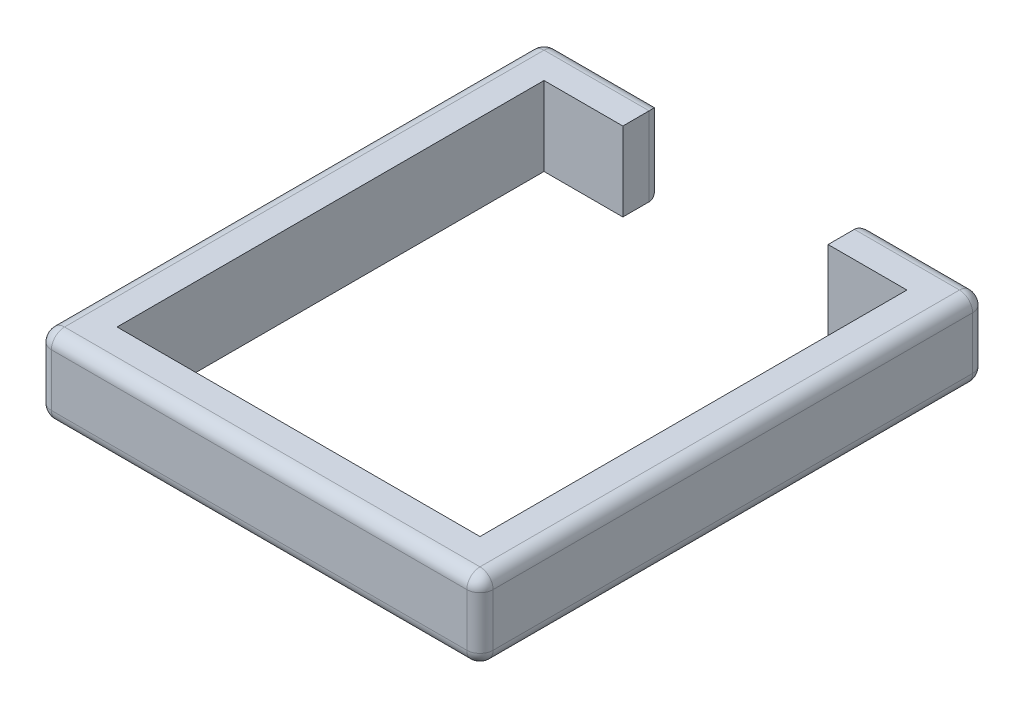
from build123d import *

# Parameters (mm, degrees)
BOSS_EXTRUDE1_DEPTH = 152.4
FILLET1_R           = 25.4


with BuildPart() as part:
    # Sketch1 → Boss-Extrude1 (new body)
    with BuildSketch(Plane(origin=(0, 0, 0), x_dir=(1, 0, 0), z_dir=(0, 1, 0))):
        Polygon((228.6, 0), (0, 0), (0, -977.9), (854.075, -977.9), (854.075, 0), (625.475, 0), (625.475, -76.2), (777.875, -76.2), (777.875, -901.7), (76.2, -901.7), (76.2, -76.2), (228.6, -76.2), align=None)
    extrude(amount=BOSS_EXTRUDE1_DEPTH)

    # Fillet1
    fillet1_edges = [part.edges().sort_by_distance(p)[0] for p in [
        (0, 152.4, 488.95),
        (427.0375, 152.4, 977.9),
        (739.775, 0, 0),
        (854.075, 0, 488.95),
        (427.0375, 0, 977.9),
        (0, 0, 488.95),
        (114.3, 0, 0),
        (854.075, 152.4, 488.95),
        (739.775, 152.4, 0),
        (625.475, 76.2, 0),
        (854.075, 76.2, 0),
        (854.075, 76.2, 977.9),
        (0, 76.2, 977.9),
        (0, 76.2, 0),
        (228.6, 76.2, 0),
        (114.3, 152.4, 0),
    ]]
    fillet(fillet1_edges, radius=FILLET1_R)


solid = part.part
